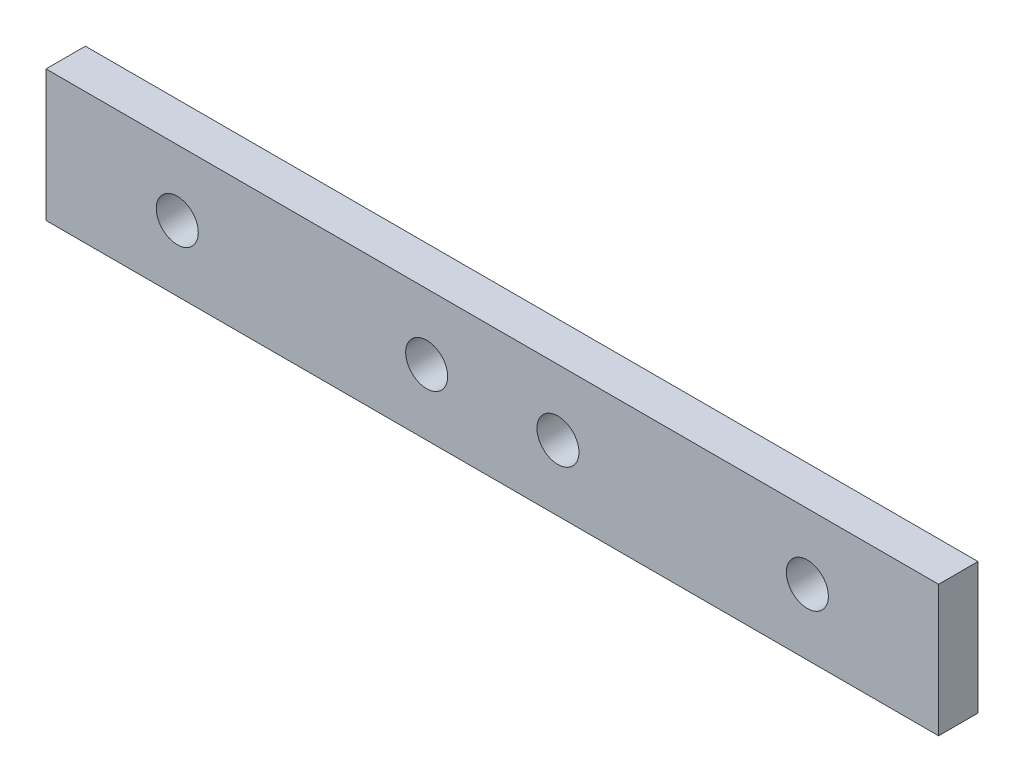
from build123d import *

# Parameters (mm, degrees)
SKETCH_1_W      = 68
SKETCH_1_H      = 10
SKETCH_1_R      = 1.6
EXTRUDE_1_DEPTH = 3


with BuildPart() as part:
    # 草图1 → 凸台-拉伸1 (new body)
    with BuildSketch(Plane.XY):
        with Locations((34, 5)):
            Rectangle(SKETCH_1_W, SKETCH_1_H)
        with Locations((29, 5)):
            Circle(SKETCH_1_R, mode=Mode.SUBTRACT)
        with Locations((39, 5)):
            Circle(SKETCH_1_R, mode=Mode.SUBTRACT)
        with Locations((10, 5)):
            Circle(SKETCH_1_R, mode=Mode.SUBTRACT)
        with Locations((58, 5)):
            Circle(SKETCH_1_R, mode=Mode.SUBTRACT)
    extrude(amount=EXTRUDE_1_DEPTH)


solid = part.part
